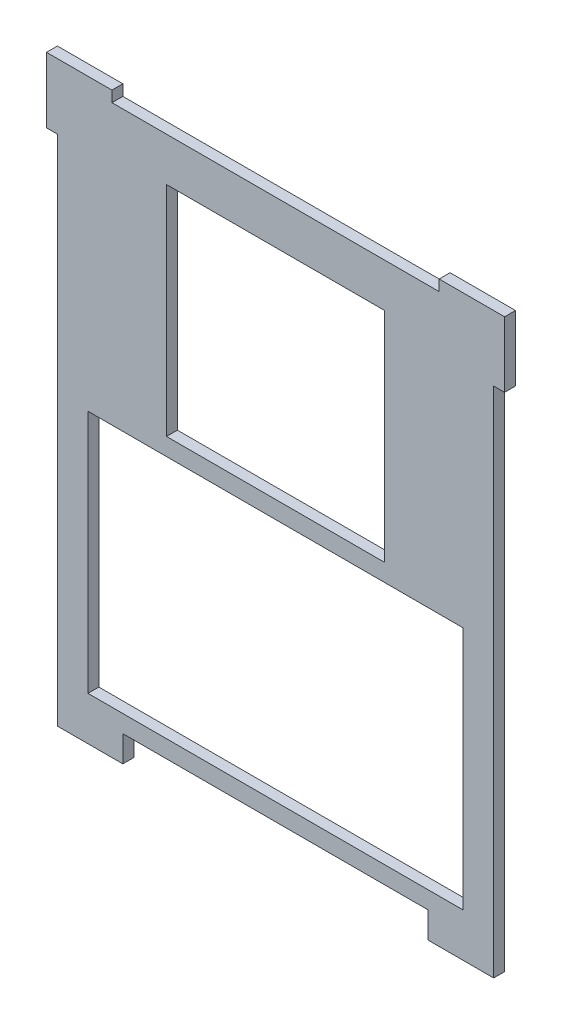
from build123d import *

# Parameters (mm, degrees)
SKETCH1_W           = 127
SKETCH1_H           = 177.8
BOSS_EXTRUDE1_DEPTH = 3.175
SKETCH3_W           = 63.5
SKETCH3_H           = 63.5
SKETCH3_W_2         = 109.22
SKETCH3_H_2         = 71.12
CUT_EXTRUDE2_DEPTH  = 4.175
BOSS_EXTRUDE2_DEPTH = 3.175
CUT_EXTRUDE3_REACH  = 5.175
SKETCH5_W           = 19.05
SKETCH5_H           = 12.7
CUT_EXTRUDE4_DEPTH  = 4.175


with BuildPart() as part:
    # Sketch1 → Boss-Extrude1 (new body)
    with BuildSketch(Plane.XY):
        Rectangle(SKETCH1_W, SKETCH1_H)
    extrude(amount=BOSS_EXTRUDE1_DEPTH)

    # Sketch3 → Cut-Extrude2 (cut, through all)
    with BuildSketch(Plane.XY.offset(3.175)):
        with Locations((0, 44.45)):
            Rectangle(SKETCH3_W, SKETCH3_H)
        with Locations((0, -27.94)):
            Rectangle(SKETCH3_W_2, SKETCH3_H_2)
    extrude(amount=-CUT_EXTRUDE2_DEPTH, mode=Mode.SUBTRACT)

    # Sketch4 → Boss-Extrude2 (add)
    with BuildSketch(Plane.XY.offset(3.175)):
        Polygon((-60.325, 92.075), (-66.675, 92.075), (-66.675, 85.725), (-66.675, 73.025), (-60.325, 73.025), (-60.325, 85.725), (-47.625, 85.725), (-47.625, 92.075), align=None)
        Polygon((60.325, 92.075), (66.675, 92.075), (66.675, 85.725), (66.675, 73.025), (60.325, 73.025), (60.325, 85.725), (47.625, 85.725), (47.625, 92.075), align=None)
    extrude(amount=-BOSS_EXTRUDE2_DEPTH)

    # Sketch5 → Cut-Extrude3 (cut, up to next)
    with BuildSketch(Plane.XY.offset(3.175), mode=Mode.PRIVATE) as cut_extrude3_sk1:
        with Locations((-53.975, -82.55)):
            Rectangle(SKETCH5_W, SKETCH5_H)
    cut_extrude3_tool1 = extrude(cut_extrude3_sk1.sketch, amount=-CUT_EXTRUDE3_REACH, mode=Mode.PRIVATE) & part.part
    add(cut_extrude3_tool1.solids().sort_by_distance((-53.975, -82.55, 3.175))[0], mode=Mode.SUBTRACT)
    # Sketch5 → Cut-Extrude3 (cut, up to next)
    with BuildSketch(Plane.XY.offset(3.175), mode=Mode.PRIVATE) as cut_extrude3_sk2:
        with Locations((53.975, -82.55)):
            Rectangle(SKETCH5_W, SKETCH5_H)
    cut_extrude3_tool2 = extrude(cut_extrude3_sk2.sketch, amount=-CUT_EXTRUDE3_REACH, mode=Mode.PRIVATE) & part.part
    add(cut_extrude3_tool2.solids().sort_by_distance((53.975, -82.55, 3.175))[0], mode=Mode.SUBTRACT)

    # Sketch6 → Cut-Extrude4 (cut, through all)
    with BuildSketch(Plane.XY.offset(3.175)):
        Polygon((-44.45, -76.2), (-44.45, -68.58), (44.45, -68.58), (44.45, -76.2), (44.45, -88.9), (-44.45, -88.9), align=None)
    extrude(amount=-CUT_EXTRUDE4_DEPTH, mode=Mode.SUBTRACT)


solid = part.part
